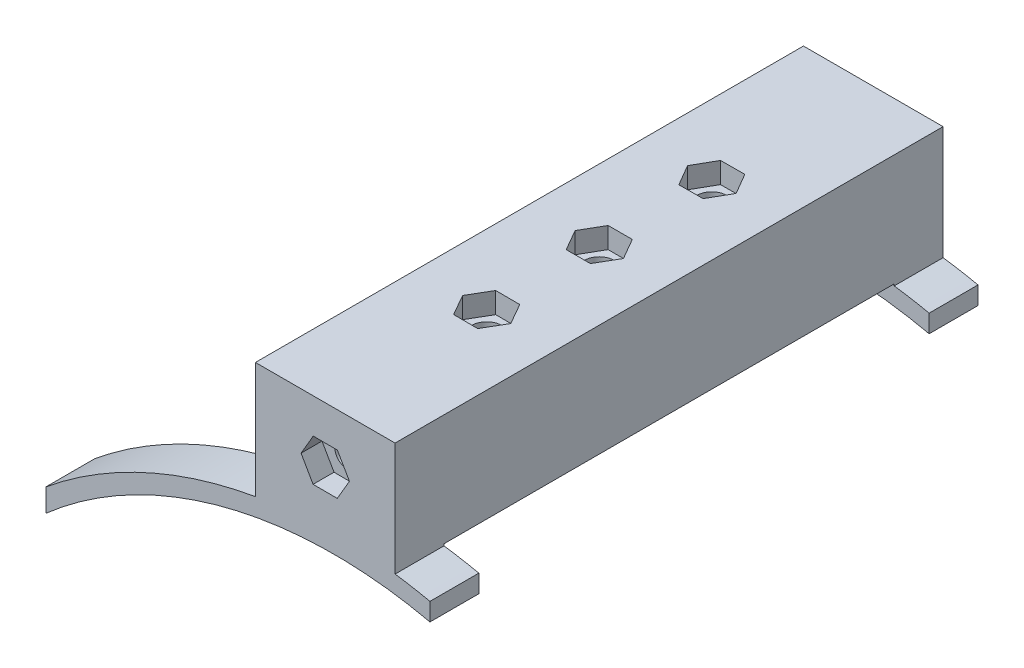
from build123d import *

# Parameters (mm, degrees)
BOSS_EXTRUDE2_DEPTH = 48.5
BOSS_EXTRUDE3_DEPTH = 18
SKETCH3_R           = 1.6
CUT_EXTRUDE1_DEPTH  = 8
CUT_EXTRUDE3_DEPTH  = 3
SKETCH5_W           = 78.5
SKETCH5_H           = 16
BOSS_EXTRUDE4_DEPTH = 2
BOSS_EXTRUDE5_DEPTH = 7
BOSS_EXTRUDE6_DEPTH = 7
SKETCH10_R          = 2.1
CUT_EXTRUDE4_DEPTH  = 17
CUT_EXTRUDE5_DEPTH  = 3
CUT_EXTRUDE6_DEPTH  = 79.5


with BuildPart() as part:
    # Sketch1 → Boss-Extrude2 (new body)
    with BuildSketch(Plane.XY):
        Polygon((0.472150472, 5.388924764), (0.472150472, 8.388924764), (-17.527849528, 8.388924764), (-17.527849528, -7.611075236), (0.472150472, -7.611075236), (0.472150472, -4.611075236), align=None)
    extrude(amount=BOSS_EXTRUDE2_DEPTH)

    # Sketch2 → Boss-Extrude3 (add)
    with BuildSketch(Plane.ZY.offset(17.527849528)):
        Polygon((48.5, 8.388924764), (62.5, 8.388924764), (63.5, 8.388924764), (63.5, 7.388924764), (63.5, -6.611075236), (63.5, -7.611075236), (62.5, -7.611075236), (48.5, -7.611075236), (48.5, -4.811075236), (48.5, 5.588924764), align=None)
        Polygon((0, -4.811075236), (0, -7.611075236), (-14, -7.611075236), (-15, -7.611075236), (-15, -6.611075236), (-15, 7.388924764), (-15, 8.388924764), (-14, 8.388924764), (0, 8.388924764), (0, 5.588924764), align=None)
    extrude(amount=-BOSS_EXTRUDE3_DEPTH)

    # Sketch3 → Cut-Extrude1 (cut)
    with BuildSketch(Plane.XY.offset(63.5)):
        with Locations((-9.527849528, 0.388924764)):
            Circle(SKETCH3_R)
    cut_extrude1 = extrude(amount=-CUT_EXTRUDE1_DEPTH, mode=Mode.SUBTRACT)

    # Mirror1: Cut-Extrude1 across plane
    add(cut_extrude1.mirror(Plane.XY.offset(24.25)), mode=Mode.SUBTRACT)

    # Sketch4 → Cut-Extrude3 (cut)
    with BuildSketch(Plane.XY.offset(63.5)):
        Polygon((-7.807950928, -2.618058576), (-6.063776267, 0.374908974), (-7.783674867, 3.381892314), (-11.247748128, 3.395908104), (-12.991922789, 0.402940554), (-11.272024189, -2.604042786), align=None)
    cut_extrude3 = extrude(amount=-CUT_EXTRUDE3_DEPTH, mode=Mode.SUBTRACT)

    # Mirror2: Cut-Extrude3 across plane
    add(cut_extrude3.mirror(Plane.XY.offset(24.25)), mode=Mode.SUBTRACT)

    # Sketch5 → Boss-Extrude4 (add)
    with BuildSketch(Plane.ZY.offset(17.527849528)):
        with Locations((24.25, 0.388924764)):
            Rectangle(SKETCH5_W, SKETCH5_H)
    extrude(amount=BOSS_EXTRUDE4_DEPTH)

    # Sketch6 → Boss-Extrude5 (add)
    with BuildSketch(Plane.XY.offset(63.5)):
        with BuildLine():
            Line((-19.527849528, -7.611075236), (-19.527849528, -8.257098609))
            ThreePointArc((-19.527849528, -8.257098609), (-29.816107458, -10.948302934), (-39.527849528, -15.28107317))
            Line((-39.527849528, -15.28107317), (-39.527849528, -18.149551009))
            ThreePointArc((-39.527849528, -18.149551009), (-8.277849528, -9.776138745), (22.972150472, -18.149551009))
            Line((22.972150472, -18.149551009), (22.972150472, -15.28107317))
            ThreePointArc((22.972150472, -15.28107317), (12.062731895, -10.540729559), (0.472150472, -7.867773606))
            Line((0.472150472, -7.867773606), (0.472150472, -7.611075236))
            Line((0.472150472, -7.611075236), (-19.527849528, -7.611075236))
        make_face()
    boss_extrude5 = extrude(amount=-BOSS_EXTRUDE5_DEPTH)

    # Mirror3: Boss-Extrude5 across plane
    add(boss_extrude5.mirror(Plane.XY.offset(24.25)))

    # Sketch7 → Boss-Extrude6 (add)
    with BuildSketch(Plane.XY.offset(63.5)):
        with BuildLine():
            Line((22.972150472, -18.149551009), (22.972150472, -15.28107317))
            ThreePointArc((22.972150472, -15.28107317), (28.129444831, -18.429050454), (32.972150472, -22.042310502))
            Line((32.972150472, -22.042310502), (32.972150472, -25.322038818))
            ThreePointArc((32.972150472, -25.322038818), (28.149113636, -21.489069971), (22.972150472, -18.149551009))
        make_face()
        with BuildLine():
            Line((-39.527849528, -15.28107317), (-39.527849528, -18.149551009))
            ThreePointArc((-39.527849528, -18.149551009), (-44.704812692, -21.489069971), (-49.527849528, -25.322038818))
            Line((-49.527849528, -25.322038818), (-49.527849528, -22.042310502))
            ThreePointArc((-49.527849528, -22.042310502), (-44.685143887, -18.429050454), (-39.527849528, -15.28107317))
        make_face()
    boss_extrude6 = extrude(amount=-BOSS_EXTRUDE6_DEPTH)

    # Mirror4: Boss-Extrude6 across plane
    add(boss_extrude6.mirror(Plane.XY.offset(24.25)))

    # Sketch10 → Cut-Extrude4 (cut, through all)
    with BuildSketch(Plane.XZ.offset(7.611075236)):
        with Locations((-9.527849528, 40.375)):
            Circle(SKETCH10_R)
        with Locations((-9.527849528, 8.125)):
            Circle(SKETCH10_R)
        with Locations((-9.527849528, 24.25)):
            Circle(SKETCH10_R)
    extrude(amount=-CUT_EXTRUDE4_DEPTH, mode=Mode.SUBTRACT)

    # Sketch11 → Cut-Extrude5 (cut)
    with BuildSketch(Plane(origin=(0, 8.388924764, 0), x_dir=(1, 0, 0), z_dir=(0, 1, 0))):
        Polygon((-7.780505993, -11.116118615), (-6.063793054, -8.107315417), (-7.811136589, -5.116196802), (-11.275193063, -5.133881385), (-12.991906002, -8.142684583), (-11.244562467, -11.133803198), align=None)
        Polygon((-11.244562467, -37.366196802), (-7.780505993, -37.383881385), (-6.063793054, -40.392684583), (-7.811136589, -43.383803198), (-11.275193063, -43.366118615), (-12.991906002, -40.357315417), align=None)
        Polygon((-6.063747913, -24.25), (-7.79579872, -21.25), (-11.259900336, -21.25), (-12.991951143, -24.25), (-11.259900336, -27.25), (-7.79579872, -27.25), align=None)
    extrude(amount=-CUT_EXTRUDE5_DEPTH, mode=Mode.SUBTRACT)

    # Sketch12 → Cut-Extrude6 (cut, through all)
    with BuildSketch(Plane.XY.offset(63.5)):
        with BuildLine():
            Line((5.472150472, -8.747109948), (5.472150472, -11.307396754))
            ThreePointArc((5.472150472, -11.307396754), (20.100884553, -16.590436344), (32.972150472, -25.322038818))
            Line((32.972150472, -25.322038818), (32.972150472, -22.042310502))
            ThreePointArc((32.972150472, -22.042310502), (20.014209242, -13.756403523), (5.472150472, -8.747109948))
        make_face()
    extrude(amount=-CUT_EXTRUDE6_DEPTH, mode=Mode.SUBTRACT)


solid = part.part
